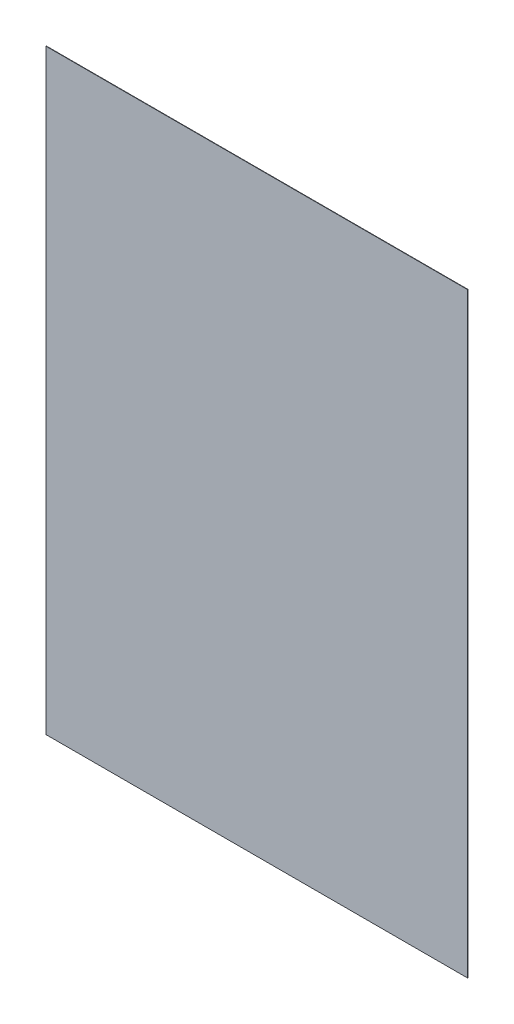
from build123d import *

# Parameters (mm, degrees)
ESQUISSE1_W        = 210
ESQUISSE1_H        = 297
BOSS_EXTRU_1_DEPTH = 0.2


with BuildPart() as part:
    # Esquisse1 → Boss.-Extru.1 (new body)
    with BuildSketch(Plane.XY):
        Rectangle(ESQUISSE1_W, ESQUISSE1_H)
    extrude(amount=BOSS_EXTRU_1_DEPTH)


solid = part.part
